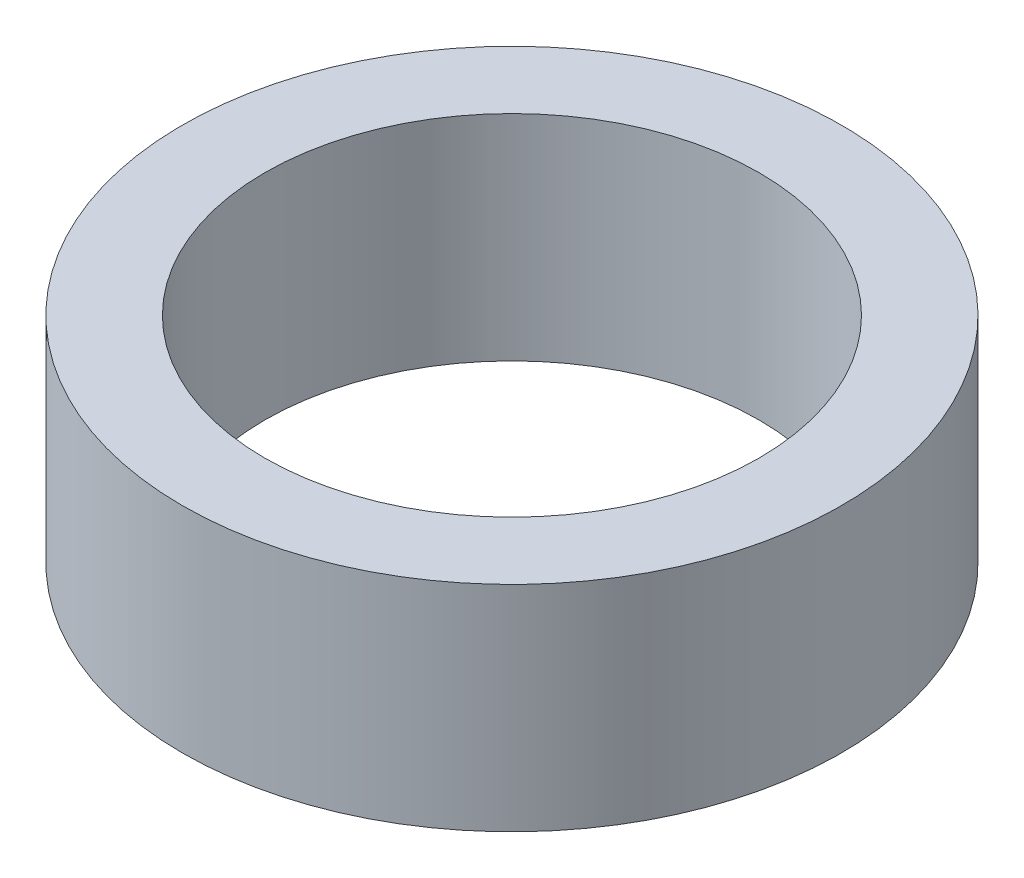
from build123d import *

# Parameters (mm, degrees)
SKETCH1_R           = 20
SKETCH1_R_2         = 15
BOSS_EXTRUDE1_DEPTH = 6.5


with BuildPart() as part:
    # Sketch1 → Boss-Extrude1 (new body, symmetric)
    with BuildSketch(Plane(origin=(0, 0, 0), x_dir=(1, 0, 0), z_dir=(0, 1, 0))):
        Circle(SKETCH1_R)
        Circle(SKETCH1_R_2, mode=Mode.SUBTRACT)
    extrude(amount=BOSS_EXTRUDE1_DEPTH, both=True)


solid = part.part
